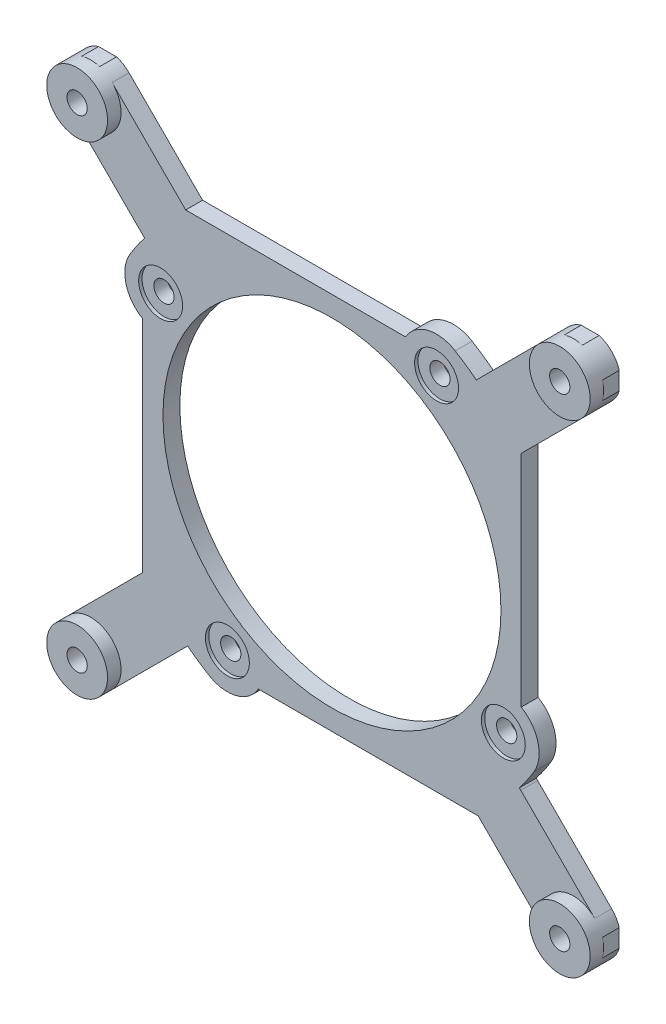
from build123d import *

# Parameters (mm, degrees)
SKETCH1_R           = 1.5
SKETCH1_R_2         = 25
BOSS_EXTRUDE1_DEPTH = 2.5
SKETCH2_R           = 3.25
CUT_EXTRUDE1_DEPTH  = 0.5
SKETCH4_R           = 4.5
SKETCH4_R_2         = 1.5
BOSS_EXTRUDE2_DEPTH = 2


with BuildPart() as part:
    # Sketch1 → Boss-Extrude1 (new body)
    with BuildSketch(Plane.XY):
        with BuildLine():
            Line((34.373350084, -40), (37.026649916, -40))
            ThreePointArc((37.026649916, -40), (38.881980515, -38.881980515), (40, -37.026649916))
            Line((40, -37.026649916), (40, -34.373350084))
            ThreePointArc((40, -34.373350084), (39.554292544, -33.377408993), (38.881980515, -32.518019485))
            Line((38.881980515, -32.518019485), (27.930717857, -21.566756826))
            ThreePointArc((27.930717857, -21.566756826), (27.826741101, -21.466071831), (27.719580149, -21.368782754))
            ThreePointArc((27.719580149, -21.368782754), (28.839517017, -19.831345346), (29.874277905, -18.235337114))
            ThreePointArc((29.874277905, -18.235337114), (30.48642799, -14.163770708), (28, -10.881994271))
            Line((28, -10.881994271), (28, 21.636038969))
            Line((28, 21.636038969), (38.881980515, 32.518019485))
            ThreePointArc((38.881980515, 32.518019485), (39.554292544, 33.377408993), (40, 34.373350084))
            Line((40, 34.373350084), (40, 37.026649916))
            ThreePointArc((40, 37.026649916), (38.881980515, 38.881980515), (37.026649916, 40))
            Line((37.026649916, 40), (34.373350084, 40))
            ThreePointArc((34.373350084, 40), (33.377408993, 39.554292544), (32.518019485, 38.881980515))
            Line((32.518019485, 38.881980515), (21.566756826, 27.930717857))
            ThreePointArc((21.566756826, 27.930717857), (21.466071831, 27.826741101), (21.368782754, 27.719580149))
            ThreePointArc((21.368782754, 27.719580149), (19.831345346, 28.839517017), (18.235337114, 29.874277905))
            ThreePointArc((18.235337114, 29.874277905), (14.163770708, 30.48642799), (10.881994271, 28))
            Line((10.881994271, 28), (-21.636038969, 28))
            Line((-21.636038969, 28), (-32.518019485, 38.881980515))
            ThreePointArc((-32.518019485, 38.881980515), (-33.377408993, 39.554292544), (-34.373350084, 40))
            Line((-34.373350084, 40), (-37.026649916, 40))
            ThreePointArc((-37.026649916, 40), (-38.881980515, 38.881980515), (-40, 37.026649916))
            Line((-40, 37.026649916), (-40, 34.373350084))
            ThreePointArc((-40, 34.373350084), (-39.554292544, 33.377408993), (-38.881980515, 32.518019485))
            Line((-38.881980515, 32.518019485), (-27.930717857, 21.566756826))
            ThreePointArc((-27.930717857, 21.566756826), (-27.826741101, 21.466071831), (-27.719580149, 21.368782754))
            ThreePointArc((-27.719580149, 21.368782754), (-28.839517017, 19.831345346), (-29.874277905, 18.235337114))
            ThreePointArc((-29.874277905, 18.235337114), (-30.48642799, 14.163770708), (-28, 10.881994271))
            Line((-28, 10.881994271), (-28, -21.636038969))
            Line((-28, -21.636038969), (-38.881980515, -32.518019485))
            ThreePointArc((-38.881980515, -32.518019485), (-39.554292544, -33.377408993), (-40, -34.373350084))
            Line((-40, -34.373350084), (-40, -37.026649916))
            ThreePointArc((-40, -37.026649916), (-38.881980515, -38.881980515), (-37.026649916, -40))
            Line((-37.026649916, -40), (-34.373350084, -40))
            ThreePointArc((-34.373350084, -40), (-33.377408993, -39.554292544), (-32.518019485, -38.881980515))
            Line((-32.518019485, -38.881980515), (-21.566756826, -27.930717857))
            ThreePointArc((-21.566756826, -27.930717857), (-21.466071831, -27.826741101), (-21.368782754, -27.719580149))
            ThreePointArc((-21.368782754, -27.719580149), (-19.831345346, -28.839517017), (-18.235337114, -29.874277905))
            ThreePointArc((-18.235337114, -29.874277905), (-14.163770708, -30.48642799), (-10.881994271, -28))
            Line((-10.881994271, -28), (21.636038969, -28))
            Line((21.636038969, -28), (32.518019485, -38.881980515))
            ThreePointArc((32.518019485, -38.881980515), (33.377408993, -39.554292544), (34.373350084, -40))
        make_face()
        with Locations((-35.7, -35.7)):
            Circle(SKETCH1_R, mode=Mode.SUBTRACT)
        with Locations((-15.473196637, -25.349165387)):
            Circle(SKETCH1_R, mode=Mode.SUBTRACT)
        with Locations((35.7, -35.7)):
            Circle(SKETCH1_R, mode=Mode.SUBTRACT)
        Circle(SKETCH1_R_2, mode=Mode.SUBTRACT)
        with Locations((25.349165387, -15.473196637)):
            Circle(SKETCH1_R, mode=Mode.SUBTRACT)
        with Locations((-25.349165387, 15.473196637)):
            Circle(SKETCH1_R, mode=Mode.SUBTRACT)
        with Locations((-35.7, 35.7)):
            Circle(SKETCH1_R, mode=Mode.SUBTRACT)
        with Locations((15.473196637, 25.349165387)):
            Circle(SKETCH1_R, mode=Mode.SUBTRACT)
        with Locations((35.7, 35.7)):
            Circle(SKETCH1_R, mode=Mode.SUBTRACT)
    extrude(amount=BOSS_EXTRUDE1_DEPTH)

    # Sketch2 → Cut-Extrude1 (cut)
    with BuildSketch(Plane.XY.offset(2.5)):
        with Locations((-15.473196637, -25.349165387)):
            Circle(SKETCH2_R)
        with Locations((25.349165387, -15.473196637)):
            Circle(SKETCH2_R)
        with Locations((15.473196637, 25.349165387)):
            Circle(SKETCH2_R)
        with Locations((-25.349165387, 15.473196637)):
            Circle(SKETCH2_R)
    extrude(amount=-CUT_EXTRUDE1_DEPTH, mode=Mode.SUBTRACT)

    # Sketch4 → Boss-Extrude2 (add)
    with BuildSketch(Plane.XY.offset(2.5)):
        with Locations((-35.7, 35.7)):
            Circle(SKETCH4_R)
        with Locations((-35.7, 35.7)):
            Circle(SKETCH4_R_2, mode=Mode.SUBTRACT)
        with Locations((35.7, 35.7)):
            Circle(SKETCH4_R)
        with Locations((35.7, 35.7)):
            Circle(SKETCH4_R_2, mode=Mode.SUBTRACT)
        with Locations((35.7, -35.7)):
            Circle(SKETCH4_R)
        with Locations((35.7, -35.7)):
            Circle(SKETCH4_R_2, mode=Mode.SUBTRACT)
        with Locations((-35.7, -35.7)):
            Circle(SKETCH4_R)
        with Locations((-35.7, -35.7)):
            Circle(SKETCH4_R_2, mode=Mode.SUBTRACT)
    extrude(amount=BOSS_EXTRUDE2_DEPTH)


solid = part.part
